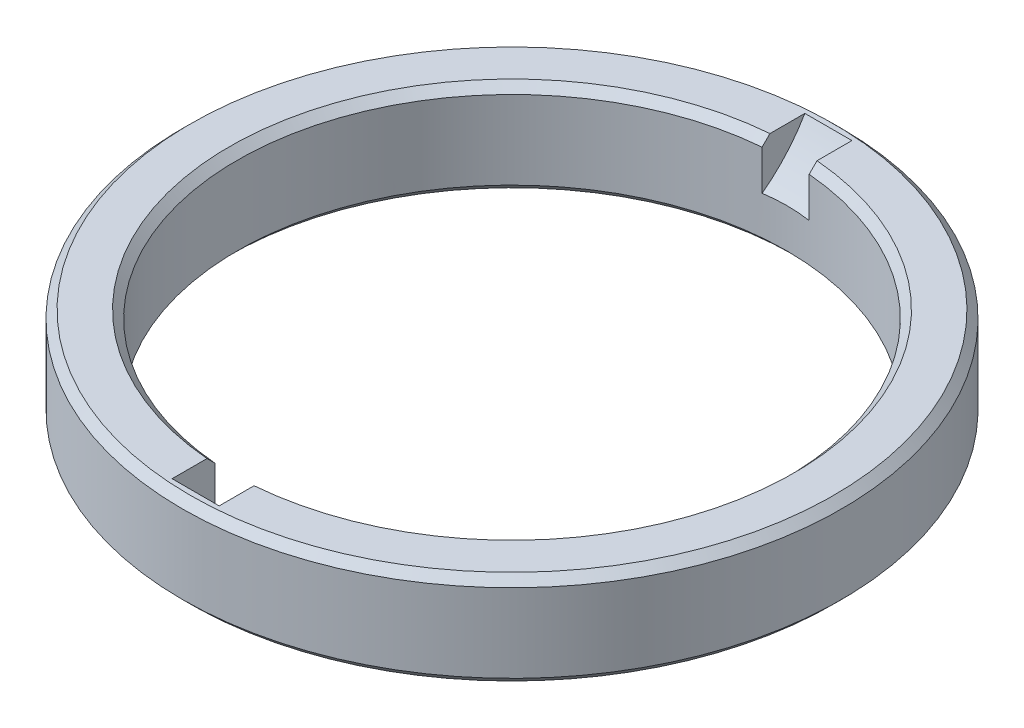
from build123d import *

# Parameters (mm, degrees)
SKETCH_2_W               = 3.5
SKETCH_2_H               = 6
CHAMFER_1_SIZE           = 0.5
CUT_EXTRUDE_2_DEPTH      = 1.5
CUT_EXTRUDE_2_DEPTH_BACK = 1.5
SKETCH_4_R               = 10


with BuildPart() as part:
    # Эскиз2 → Повернуть1 (revolve)
    with BuildSketch(Plane.XY):
        with Locations((19.25, 3)):
            Rectangle(SKETCH_2_W, SKETCH_2_H)
    revolve(axis=Axis((0, 0, 0), (0, 1, 0)))

    # Фаска1
    chamfer_1_edges = [part.edges().sort_by_distance(p)[0] for p in [
        (-21, 6, 0),
        (-21, 0, 0),
        (-17.5, 0, 0),
        (-17.5, 6, 0),
    ]]
    chamfer(chamfer_1_edges, length=CHAMFER_1_SIZE)

    # Эскиз4 → Вырез-Вытянуть2 (cut, two sides: drawn at the far end of the back side and taken through both)
    with BuildSketch(Plane(origin=(0, 0, 0), x_dir=(0, 0, -1), z_dir=(1, 0, 0)).offset(-CUT_EXTRUDE_2_DEPTH_BACK)):
        with Locations((-11.5, 11)):
            Circle(SKETCH_4_R)
        with Locations((11.5, 11)):
            Circle(SKETCH_4_R)
    extrude(amount=CUT_EXTRUDE_2_DEPTH + CUT_EXTRUDE_2_DEPTH_BACK, mode=Mode.SUBTRACT)


solid = part.part
